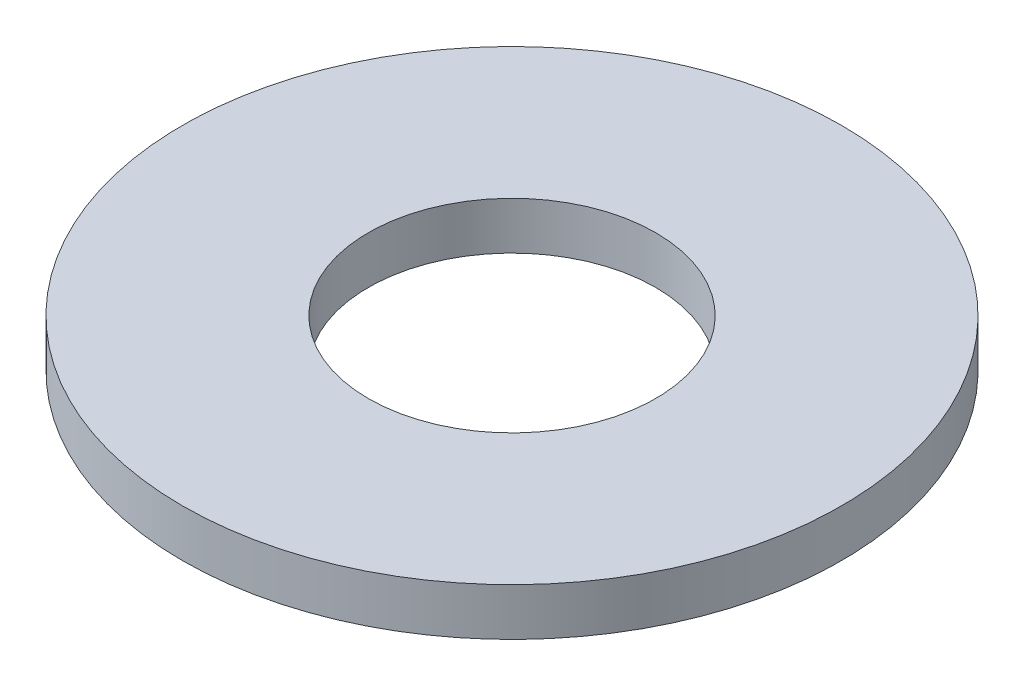
from build123d import *

# Parameters (mm, degrees)
SKETCH1_R           = 3.175
BOSS_EXTRUDE1_DEPTH = 0.4572
SKETCH5_R           = 1.3843
CUT_EXTRUDE1_DEPTH  = 1.4572


with BuildPart() as part:
    # Sketch1 → Boss-Extrude1 (new body)
    with BuildSketch(Plane(origin=(0, 0, 0), x_dir=(1, 0, 0), z_dir=(0, 1, 0))):
        Circle(SKETCH1_R)
    extrude(amount=BOSS_EXTRUDE1_DEPTH)

    # Sketch5 → Cut-Extrude1 (cut, through all)
    with BuildSketch(Plane(origin=(0, 0.4572, 0), x_dir=(-1, 0, 0), z_dir=(0, 1, 0))):
        Circle(SKETCH5_R)
    extrude(amount=-CUT_EXTRUDE1_DEPTH, mode=Mode.SUBTRACT)


solid = part.part
